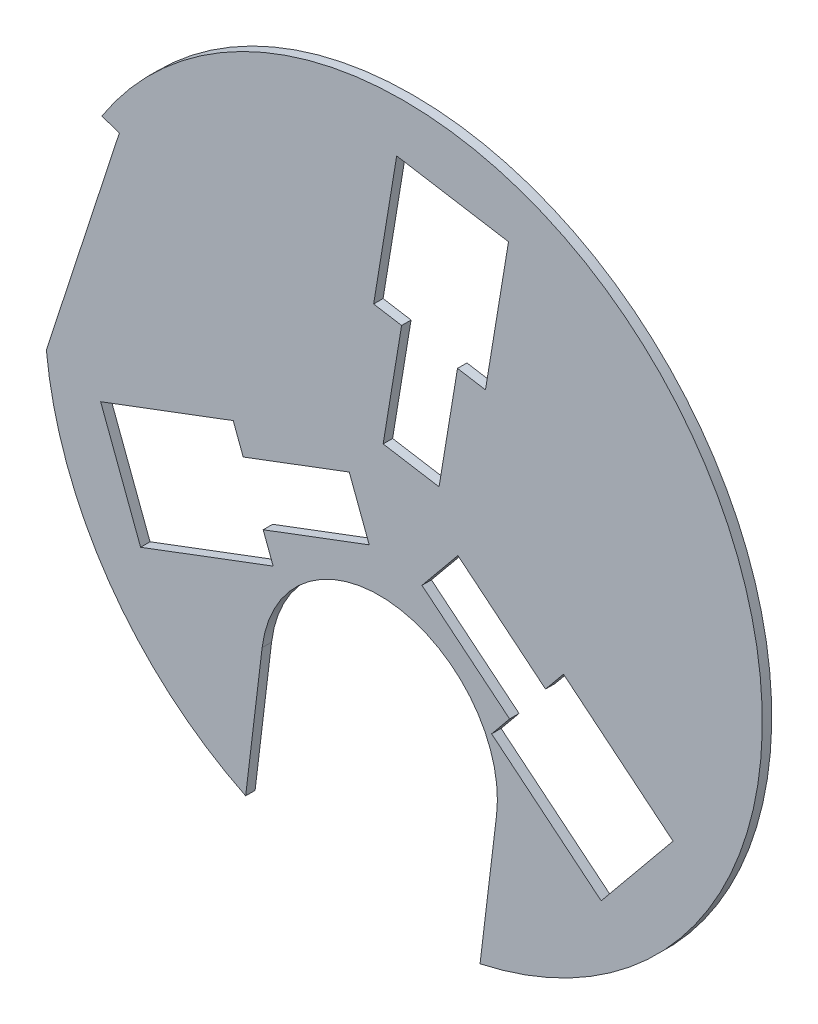
from build123d import *

# Parameters (mm, degrees)
BOSS_EXTRUDE1_DEPTH = 5


with BuildPart() as part:
    # Sketch1 → Boss-Extrude1 (new body)
    with BuildSketch(Plane.XY):
        with BuildLine():
            Line((-83.530674823, -170.653527252), (-74.806628793, -98.304799508))
            ThreePointArc((-74.806628793, -98.304799508), (-5.273873885, -43.7365304), (49.294395236, -113.269285297))
            Line((49.294395236, -113.269285297), (40.570349206, -185.618013041))
            ThreePointArc((40.570349206, -185.618013041), (156.087114581, 108.336571211), (-159.704253129, 102.929837912))
            Line((-159.704253129, 102.929837912), (-150.380705265, 99.896734946))
            Line((-150.380705265, 99.896734946), (-189.050478899, -18.971463523))
            ThreePointArc((-189.050478899, -18.971463523), (-155.971098141, -108.503532406), (-83.530674823, -170.653527252))
        make_face()
        Polygon((-74.257311019, -43.998315425), (-68.970068444, -58.035589589), (-139.156439262, -84.471802466), (-160.305409564, -28.322705811), (-90.119038745, -1.886492934), (-84.83179617, -15.923767097), (-28.682699515, 5.225203205), (-18.108214364, -22.849345123), align=None, mode=Mode.SUBTRACT)
        Polygon((-0.975003372, 86.307875472), (-15.775260686, 88.747626167), (-3.576507208, 162.748912734), (55.624522046, 152.989909952), (43.425768568, 78.988623385), (28.625511255, 81.428374081), (18.866508473, 22.227344827), (-10.734006154, 27.106846218), align=None, mode=Mode.SUBTRACT)
        Polygon((75.232314391, -42.309560047), (84.745329129, -30.712036579), (142.73294647, -78.277110268), (104.680887518, -124.667204141), (46.693270177, -77.102130451), (56.206284915, -65.504606983), (9.816191042, -27.452548031), (28.842220518, -4.257501095), align=None, mode=Mode.SUBTRACT)
    extrude(amount=BOSS_EXTRUDE1_DEPTH)


solid = part.part
